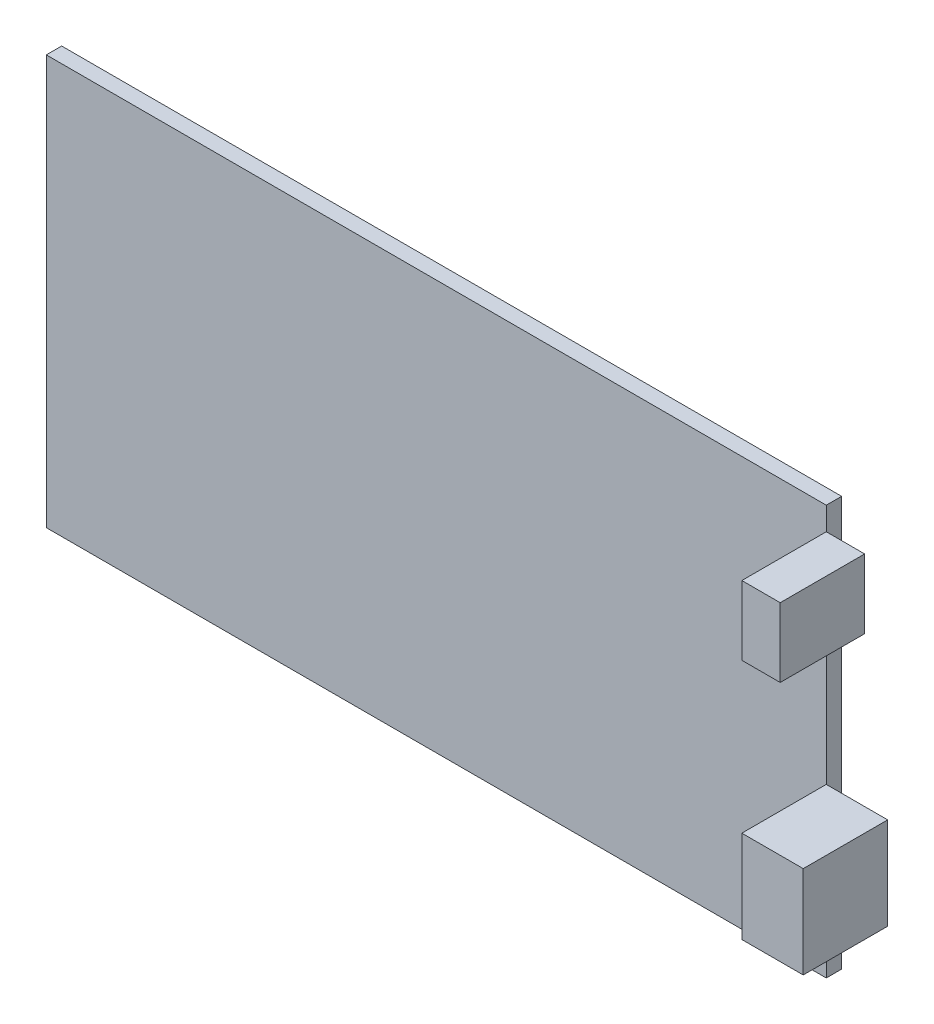
from build123d import *

# Parameters (mm, degrees)
ESBO_O1_W                  = 101.6
ESBO_O1_H                  = 53.34
RESSALTO_EXTRUS_O1_DEPTH   = 2
ESBO_O2_W                  = 11
ESBO_O2_H                  = 9
RESSALTO_EXTRUS_O2_DEPTH   = 5
ESBO_O2_H_2                = 12
RESSALTO_EXTRUS_O2_2_DEPTH = 5
ESBO_O3_W                  = 11
ESBO_O3_H                  = 12
RESSALTO_EXTRUS_O3_DEPTH   = 3


with BuildPart() as part:
    # Esboço1 → Ressalto-extrusão1 (new body)
    with BuildSketch(Plane.XY):
        with Locations((50.8, 26.67)):
            Rectangle(ESBO_O1_W, ESBO_O1_H)
    extrude(amount=RESSALTO_EXTRUS_O1_DEPTH)


with BuildPart() as body_2:
    # Esboço2 → Ressalto-extrusão2 (new body)
    with BuildSketch(Plane(origin=(101.6, 0, 0), x_dir=(0, 0, -1), z_dir=(1, 0, 0))):
        with Locations((-7.5, 45.84)):
            Rectangle(ESBO_O2_W, ESBO_O2_H)
    extrude(amount=RESSALTO_EXTRUS_O2_DEPTH)


with BuildPart() as body_3:
    # Esboço2 → Ressalto-extrus_o2 2 (new body)
    with BuildSketch(Plane(origin=(101.6, 0, 0), x_dir=(0, 0, -1), z_dir=(1, 0, 0))):
        with Locations((-7.5, 15.84)):
            Rectangle(ESBO_O2_W, ESBO_O2_H_2)
    extrude(amount=RESSALTO_EXTRUS_O2_2_DEPTH)

    # Esboço3 → Ressalto-extrusão3 (add)
    with BuildSketch(Plane(origin=(106.6, 0, 0), x_dir=(0, 0, -1), z_dir=(1, 0, 0))):
        with Locations((-7.5, 15.84)):
            Rectangle(ESBO_O3_W, ESBO_O3_H)
    extrude(amount=RESSALTO_EXTRUS_O3_DEPTH)


solid = Compound([part.part, body_2.part, body_3.part])
